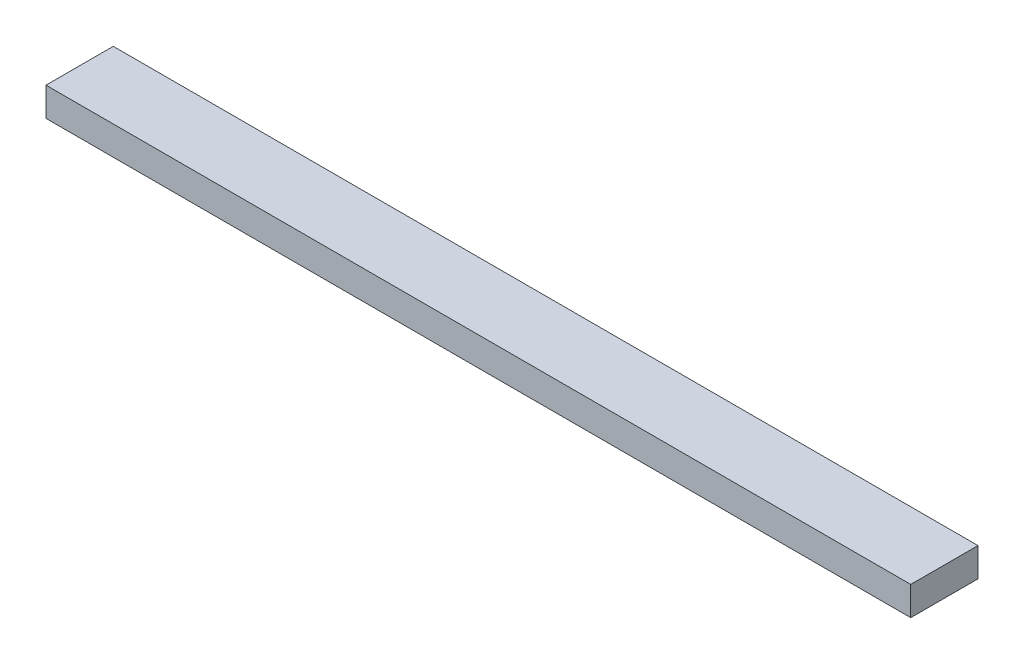
from build123d import *

# Parameters (mm, degrees)
SKETCH1_W           = 1143
SKETCH1_H           = 88.9
BOSS_EXTRUDE1_DEPTH = 38.1


with BuildPart() as part:
    # Sketch1 → Boss-Extrude1 (new body)
    with BuildSketch(Plane(origin=(0, 0, 0), x_dir=(1, 0, 0), z_dir=(0, 1, 0))):
        with Locations((571.5, 44.45)):
            Rectangle(SKETCH1_W, SKETCH1_H)
    extrude(amount=BOSS_EXTRUDE1_DEPTH)


solid = part.part
